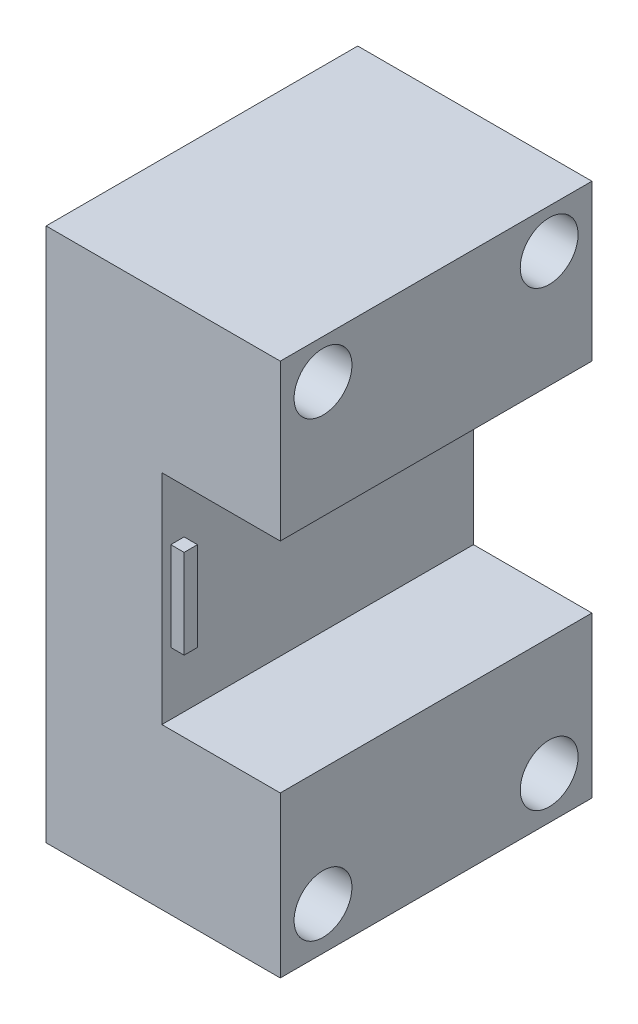
from build123d import *

# Parameters (mm, degrees)
SKETCH1_W           = 13
SKETCH1_H           = 60
BOSS_EXTRUDE1_DEPTH = 35
SKETCH3_W           = 1.5
SKETCH3_H           = 10
BOSS_EXTRUDE2_DEPTH = 1.5
SKETCH7_W           = 13.3
SKETCH7_H           = 17.5
SKETCH7_H_2         = 18
BOSS_EXTRUDE6_DEPTH = 35
SKETCH11_R          = 3.25
CUT_EXTRUDE2_DEPTH  = 27.3


with BuildPart() as part:
    # Sketch1 → Boss-Extrude1 (new body)
    with BuildSketch(Plane.XY):
        with Locations((6.5, 30)):
            Rectangle(SKETCH1_W, SKETCH1_H)
    extrude(amount=-BOSS_EXTRUDE1_DEPTH)

    # Sketch3 → Boss-Extrude2 (add)
    with BuildSketch(Plane(origin=(13, 0, 0), x_dir=(0, 0, -1), z_dir=(1, 0, 0))):
        with Locations((1.75, 30)):
            Rectangle(SKETCH3_W, SKETCH3_H)
    extrude(amount=BOSS_EXTRUDE2_DEPTH)

    # Sketch7 → Boss-Extrude6 (add)
    with BuildSketch(Plane.XY):
        with Locations((19.65, 51.25)):
            Rectangle(SKETCH7_W, SKETCH7_H)
        with Locations((19.65, 9)):
            Rectangle(SKETCH7_W, SKETCH7_H_2)
    extrude(amount=-BOSS_EXTRUDE6_DEPTH)

    # Sketch11 → Cut-Extrude2 (cut, through all)
    with BuildSketch(Plane(origin=(26.3, 0, 0), x_dir=(0, 0, -1), z_dir=(1, 0, 0))):
        with Locations((4.8, 4.8)):
            Circle(SKETCH11_R)
        with Locations((30.2, 4.8)):
            Circle(SKETCH11_R)
        with Locations((30.2, 55.6)):
            Circle(SKETCH11_R)
        with Locations((4.8, 55.6)):
            Circle(SKETCH11_R)
    extrude(amount=-CUT_EXTRUDE2_DEPTH, mode=Mode.SUBTRACT)


solid = part.part
